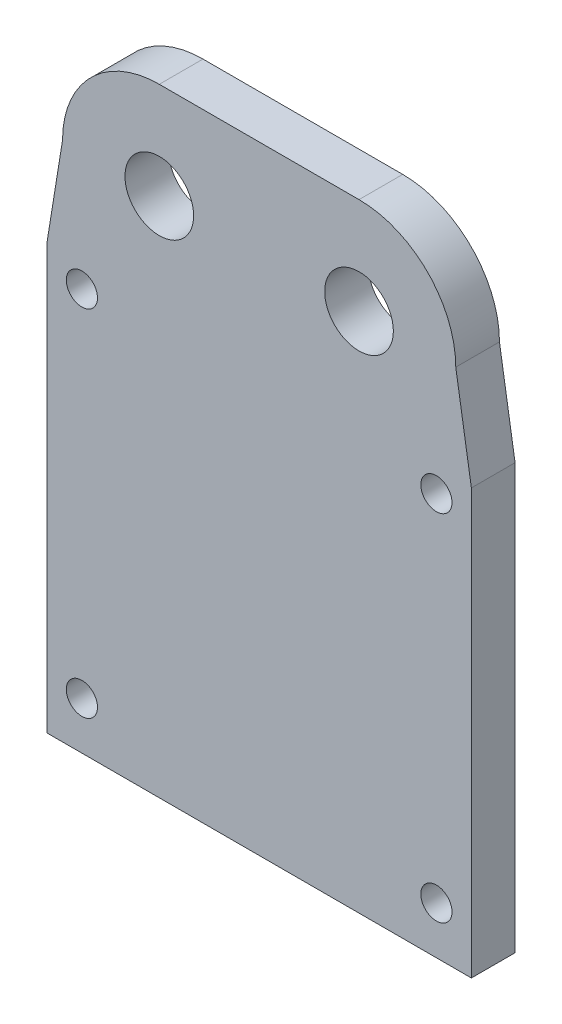
from build123d import *

# Parameters (mm, degrees)
SKETCH1_R           = 2.75
BOSS_EXTRUDE1_DEPTH = 10
BOSS_EXTRUDE4_DEPTH = 10
SKETCH7_W           = 25
SKETCH7_H           = 2
BOSS_EXTRUDE6_DEPTH = 2
SKETCH8_R           = 1.25
CUT_EXTRUDE3_DEPTH  = 19
SKETCH9_W           = 25
SKETCH9_H           = 29.5
BOSS_EXTRUDE7_DEPTH = 10
SKETCH10_W          = 16
SKETCH10_H          = 6.5
CUT_EXTRUDE4_DEPTH  = 54


with BuildPart() as part:
    # Sketch1 → Boss-Extrude1 (new body)
    with BuildSketch(Plane.XY):
        with BuildLine():
            Line((8, 7.75), (-8, 7.75))
            ThreePointArc((-8, 7.75), (-15.75, 0), (-8, -7.75))
            Line((-8, -7.75), (8, -7.75))
            ThreePointArc((8, -7.75), (15.75, 0), (8, 7.75))
        make_face()
        with Locations((-8, 0)):
            Circle(SKETCH1_R, mode=Mode.SUBTRACT)
        with Locations((8, 0)):
            Circle(SKETCH1_R, mode=Mode.SUBTRACT)
    extrude(amount=BOSS_EXTRUDE1_DEPTH)

    # Sketch5 → Boss-Extrude4 (add)
    with BuildSketch(Plane.XY):
        Polygon((-12.5, -7.75), (-17, -7.75), (-17, -41.75), (17, -41.75), (17, -7.75), (12.5, -7.75), (12.5, -12.25), (12.5, -37.25), (-12.5, -37.25), (-12.5, -12.25), align=None)
        with BuildLine():
            ThreePointArc((-8, -7.75), (-13.480077554, -5.480077554), (-15.75, 0))
            Line((-15.75, 0), (-17, -7.75))
            Line((-17, -7.75), (-12.5, -7.75))
            Line((-12.5, -7.75), (-8, -7.75))
        make_face()
        with BuildLine():
            ThreePointArc((15.75, 0), (13.480077554, -5.480077554), (8, -7.75))
            Line((8, -7.75), (12.5, -7.75))
            Line((12.5, -7.75), (17, -7.75))
            Line((17, -7.75), (15.75, 0))
        make_face()
    extrude(amount=BOSS_EXTRUDE4_DEPTH)

    # Sketch7 → Boss-Extrude6 (add)
    with BuildSketch(Plane.XY.offset(10)):
        with Locations((0, -6.75)):
            Rectangle(SKETCH7_W, SKETCH7_H)
    extrude(amount=BOSS_EXTRUDE6_DEPTH)

    # Sketch8 → Cut-Extrude3 (cut)
    with BuildSketch(Plane.XY.offset(10)):
        with Locations((-14.2, -9.55)):
            Circle(SKETCH8_R)
        with Locations((14.2, -9.55)):
            Circle(SKETCH8_R)
        with Locations((14.2, -37.95)):
            Circle(SKETCH8_R)
        with Locations((-14.2, -37.95)):
            Circle(SKETCH8_R)
    extrude(amount=-CUT_EXTRUDE3_DEPTH, mode=Mode.SUBTRACT)

    # Sketch9 → Boss-Extrude7 (add)
    with BuildSketch(Plane(origin=(0, 0, 0), x_dir=(-1, 0, 0), z_dir=(0, 0, -1))):
        with Locations((0, -22.5)):
            Rectangle(SKETCH9_W, SKETCH9_H)
    extrude(amount=-BOSS_EXTRUDE7_DEPTH)

    # Sketch10 → Cut-Extrude4 (cut)
    with BuildSketch(Plane(origin=(0, 7.75, 0), x_dir=(1, 0, 0), z_dir=(0, 1, 0))):
        Polygon((-8, -3.5), (-17, -3.5), (-17, -13.303899359), (17, -13.303899359), (17, -3.5), (8, -3.5), (8, -10), (-8, -10), align=None)
        with Locations((0, -6.75)):
            Rectangle(SKETCH10_W, SKETCH10_H)
    extrude(amount=-CUT_EXTRUDE4_DEPTH, mode=Mode.SUBTRACT)


solid = part.part
